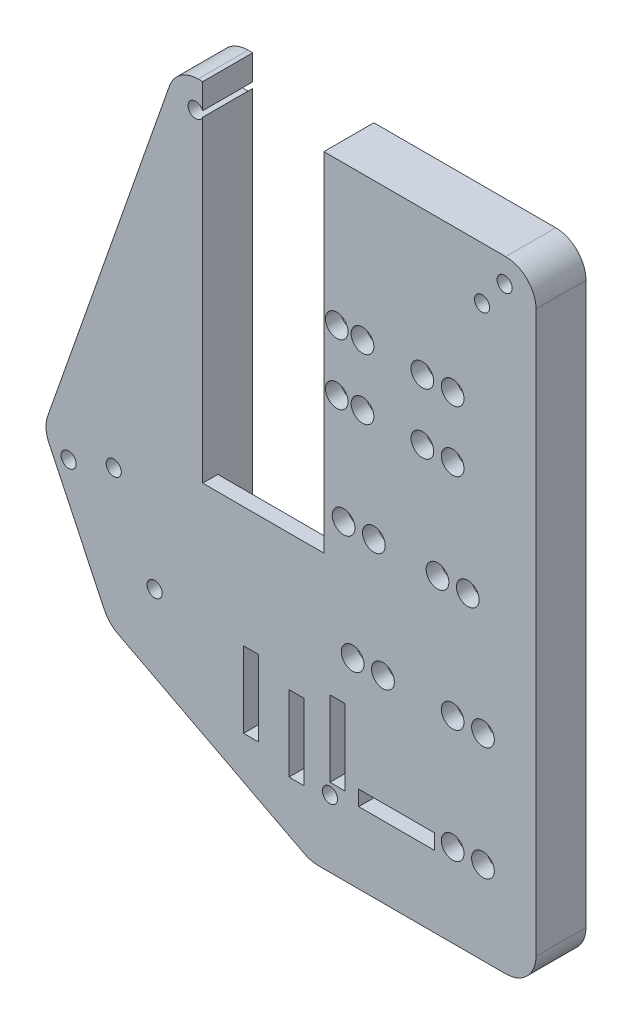
from build123d import *

# Parameters (mm, degrees)
BOSS_EXTRUDE1_DEPTH     = 2.54
SKETCH4_R               = 1.905
SKETCH4_W               = 20.32
SKETCH4_H               = 50.8
CUT_EXTRUDE2_DEPTH      = 25.4
SKETCH5_W               = 20.32
SKETCH5_H               = 7.493
CUT_EXTRUDE3_DEPTH      = 5.08
SKETCH8_W               = 12.7
SKETCH8_H               = 2.54
SKETCH8_W_2             = 2.54
SKETCH8_H_2             = 12.7
CUT_EXTRUDE5_DEPTH      = 5.08
BOSS_EXTRUDE2_DEPTH     = 5.842
SKETCH10_R              = 1.27
CUT_EXTRUDE6_DEPTH      = 1
CUT_EXTRUDE6_DEPTH_BACK = 9.382
SKETCH6_R               = 1.27
CUT_EXTRUDE7_DEPTH      = 1
CUT_EXTRUDE7_DEPTH_BACK = 9.382


with BuildPart() as part:
    # Sketch1 → Boss-Extrude1 (new body)
    with BuildSketch(Plane.XY):
        with BuildLine():
            Line((-3.314058103, 6.35), (48.26, 6.35))
            ThreePointArc((48.26, 6.35), (51.852102448, 4.862102448), (53.34, 1.27))
            Line((53.34, 1.27), (53.34, -92.71))
            ThreePointArc((53.34, -92.71), (51.852102448, -96.302102448), (48.26, -97.79))
            Line((48.26, -97.79), (16.846989059, -97.79))
            ThreePointArc((16.846989059, -97.79), (15.638688158, -97.644208035), (14.499741809, -97.215200367))
            Line((14.499741809, -97.215200367), (-16.7505185, -80.933552139))
            ThreePointArc((-16.7505185, -80.933552139), (-18.059258376, -79.955412607), (-18.989802686, -78.61241436))
            Line((-18.989802686, -78.61241436), (-28.309569459, -59.040904135))
            ThreePointArc((-28.309569459, -59.040904135), (-28.795802898, -57.127870198), (-28.51617555, -55.173917704))
            Line((-28.51617555, -55.173917704), (-8.107195629, 2.952923842))
            ThreePointArc((-8.107195629, 2.952923842), (-6.251501454, 5.414614163), (-3.314058103, 6.35))
        make_face()
    extrude(amount=BOSS_EXTRUDE1_DEPTH)

    # Sketch4 → Cut-Extrude2 (cut)
    with BuildSketch(Plane(origin=(0, 0, 0), x_dir=(-1, 0, 0), z_dir=(0, 0, -1))):
        with Locations((-39.37, -17.78)):
            Circle(SKETCH4_R)
        with Locations((-34.29, -17.78)):
            Circle(SKETCH4_R)
        with Locations((-39.37, -27.94)):
            Circle(SKETCH4_R)
        with Locations((-34.29, -27.94)):
            Circle(SKETCH4_R)
        with Locations((-41.91, -45.72)):
            Circle(SKETCH4_R)
        with Locations((-36.83, -45.72)):
            Circle(SKETCH4_R)
        with Locations((-44.45, -64.77)):
            Circle(SKETCH4_R)
        with Locations((-39.37, -64.77)):
            Circle(SKETCH4_R)
        with Locations((-44.45, -83.82)):
            Circle(SKETCH4_R)
        with Locations((-39.37, -83.82)):
            Circle(SKETCH4_R)
        with Locations((-24.257, -17.78)):
            Circle(SKETCH4_R)
        with Locations((-19.939, -17.78)):
            Circle(SKETCH4_R)
        with Locations((-24.257, -27.94)):
            Circle(SKETCH4_R)
        with Locations((-19.939, -27.94)):
            Circle(SKETCH4_R)
        with Locations((-26.162, -45.72)):
            Circle(SKETCH4_R)
        with Locations((-21.082, -45.72)):
            Circle(SKETCH4_R)
        with Locations((-27.686, -64.77)):
            Circle(SKETCH4_R)
        with Locations((-22.606, -64.77)):
            Circle(SKETCH4_R)
        with Locations((-7.62, -26.543)):
            Rectangle(SKETCH4_W, SKETCH4_H)
    extrude(amount=-CUT_EXTRUDE2_DEPTH, mode=Mode.SUBTRACT)

    # Sketch5 → Cut-Extrude3 (cut)
    with BuildSketch(Plane.XY.offset(2.54)):
        with Locations((7.62, 2.6035)):
            Rectangle(SKETCH5_W, SKETCH5_H)
    extrude(amount=-CUT_EXTRUDE3_DEPTH, mode=Mode.SUBTRACT)

    # Sketch8 → Cut-Extrude5 (cut)
    with BuildSketch(Plane.XY.offset(2.54)):
        with Locations((29.972, -84.5566)):
            Rectangle(SKETCH8_W, SKETCH8_H)
        with Locations((20.066, -78.359)):
            Rectangle(SKETCH8_W_2, SKETCH8_H_2)
        with Locations((13.208, -81.026)):
            Rectangle(SKETCH8_W_2, SKETCH8_H_2)
        with Locations((5.588, -78.486)):
            Rectangle(SKETCH8_W_2, SKETCH8_H_2)
    extrude(amount=-CUT_EXTRUDE5_DEPTH, mode=Mode.SUBTRACT)

    # Sketch9 → Boss-Extrude2 (add)
    with BuildSketch(Plane(origin=(0, 0, 0), x_dir=(-1, 0, 0), z_dir=(0, 0, -1))):
        with BuildLine():
            Line((-48.26, -97.79), (-48.26, 1.27))
            Line((-48.26, 1.27), (-17.78, 1.27))
            Line((-17.78, 1.27), (-17.78, 6.35))
            Line((-17.78, 6.35), (-48.26, 6.35))
            ThreePointArc((-48.26, 6.35), (-51.852102448, 4.862102448), (-53.34, 1.27))
            Line((-53.34, 1.27), (-53.34, -92.71))
            ThreePointArc((-53.34, -92.71), (-51.852102448, -96.302102448), (-48.26, -97.79))
        make_face()
        with BuildLine():
            Line((2.54, -82.609215784), (2.54, 6.35))
            Line((2.54, 6.35), (3.314058103, 6.35))
            ThreePointArc((3.314058103, 6.35), (6.251501454, 5.414614163), (8.107195629, 2.952923842))
            Line((8.107195629, 2.952923842), (28.51617555, -55.173917704))
            ThreePointArc((28.51617555, -55.173917704), (28.795802898, -57.127870198), (28.309569459, -59.040904135))
            Line((28.309569459, -59.040904135), (18.989802686, -78.61241436))
            ThreePointArc((18.989802686, -78.61241436), (18.059258376, -79.955412607), (16.7505185, -80.933552139))
            Line((16.7505185, -80.933552139), (-14.499741809, -97.215200367))
            ThreePointArc((-14.499741809, -97.215200367), (-15.638688158, -97.644208035), (-16.846989059, -97.79))
            Line((-16.846989059, -97.79), (-16.846989059, -92.71))
            Line((-16.846989059, -92.71), (2.54, -82.609215784))
        make_face()
    extrude(amount=BOSS_EXTRUDE2_DEPTH)

    # Sketch10 → Cut-Extrude6 (cut, two sides)
    with BuildSketch(Plane.XY.offset(2.54)) as cut_extrude6_sk:
        with Locations((48.0822, 2.286)):
            Circle(SKETCH10_R)
        with Locations((-3.718687848, 1.651)):
            Circle(SKETCH10_R)
        with Locations((-25.012261453, -59.761967182)):
            Circle(SKETCH10_R)
    extrude(amount=CUT_EXTRUDE6_DEPTH, mode=Mode.SUBTRACT)
    extrude(cut_extrude6_sk.sketch, amount=-CUT_EXTRUDE6_DEPTH_BACK, mode=Mode.SUBTRACT)

    # Sketch6 → Cut-Extrude7 (cut, two sides)
    with BuildSketch(Plane.XY.offset(2.54)) as cut_extrude7_sk:
        with Locations((1.6002, -2.4384)):
            Circle(SKETCH6_R)
        with Locations((44.2976, -2.4384)):
            Circle(SKETCH6_R)
        with Locations((-17.4498, -57.15)):
            Circle(SKETCH6_R)
        with Locations((-10.5918, -71.3486)):
            Circle(SKETCH6_R)
        with Locations((18.796, -86.5378)):
            Circle(SKETCH6_R)
    extrude(amount=CUT_EXTRUDE7_DEPTH, mode=Mode.SUBTRACT)
    extrude(cut_extrude7_sk.sketch, amount=-CUT_EXTRUDE7_DEPTH_BACK, mode=Mode.SUBTRACT)


solid = part.part
